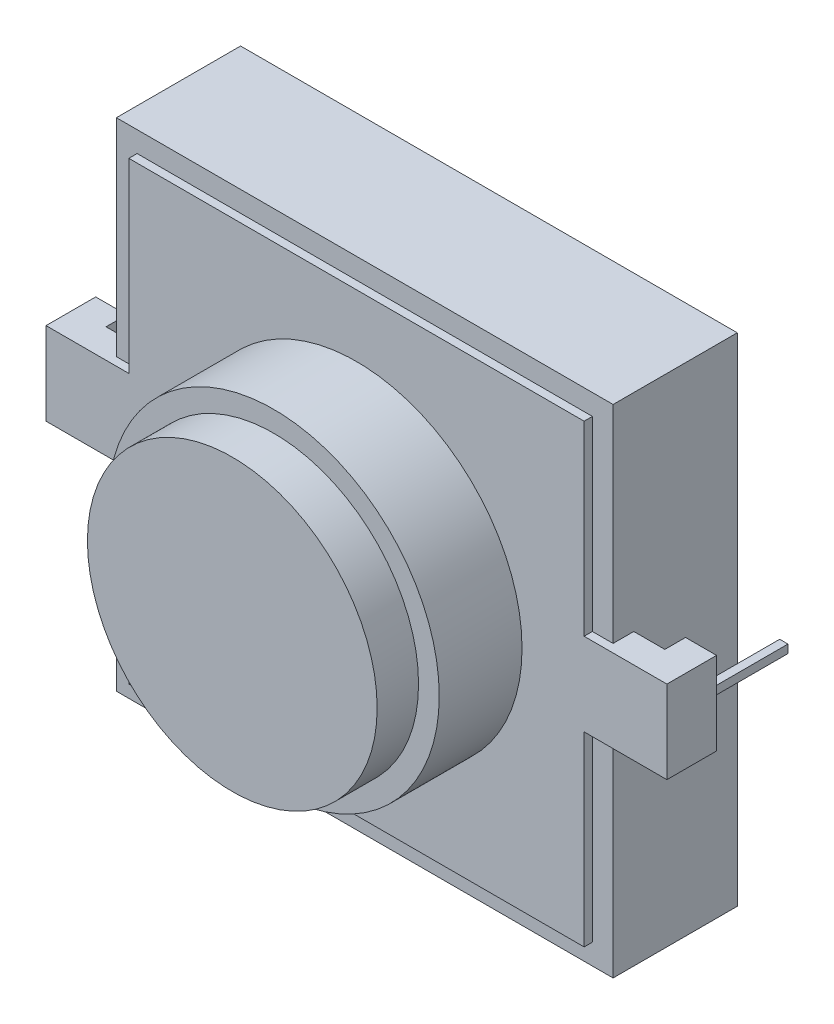
from build123d import *

# Parameters (mm, degrees)
ESQUISSE1_W             = 12
ESQUISSE1_H             = 12
BOSS_EXTRU_1_DEPTH      = 3
BOSS_EXTRU_2_DEPTH      = 0.2
BOSS_EXTRU_3_DEPTH      = 1
ESQUISSE4_W             = 0.2
ESQUISSE4_H             = 2
BOSS_EXTRU_4_DEPTH      = 0.1
ESQUISSE5_R             = 4
BOSS_EXTRU_5_DEPTH      = 2
ESQUISSE6_R             = 3.5
ENL_V_MAT_EXTRU_1_DEPTH = 2
ESQUISSE7_R             = 3.5
BOSS_EXTRU_6_DEPTH      = 3


with BuildPart() as part:
    # Esquisse1 → Boss.-Extru.1 (new body)
    with BuildSketch(Plane.XY):
        Rectangle(ESQUISSE1_W, ESQUISSE1_H)
    extrude(amount=BOSS_EXTRU_1_DEPTH)

    # Esquisse2 → Boss.-Extru.2 (add)
    with BuildSketch(Plane.XY.offset(3)):
        Polygon((-5.5, 1), (-5.5, 5.5), (5.5, 5.5), (5.5, 1), (7.5, 1), (7.5, -1), (5.5, -1), (5.5, -5.5), (-5.5, -5.5), (-5.5, -1), (-7.5, -1), (-7.5, 1), align=None)
    extrude(amount=BOSS_EXTRU_2_DEPTH)

    # Esquisse3 → Boss.-Extru.3 (add, symmetric)
    with BuildSketch(Plane(origin=(0, 0, 0), x_dir=(1, 0, 0), z_dir=(0, 1, 0))):
        Polygon((6, -3), (6, -2.5), (6.75, -2.5), (6.75, -2), (7.5, -2), (7.5, -3), align=None)
        Polygon((-7.5, -3), (-6, -3), (-6, -2.5), (-6.75, -2.5), (-6.75, -2), (-7.5, -2), align=None)
    extrude(amount=BOSS_EXTRU_3_DEPTH, both=True)

    # Esquisse4 → Boss.-Extru.4 (add, symmetric)
    with BuildSketch(Plane(origin=(0, 0, 0), x_dir=(1, 0, 0), z_dir=(0, 1, 0))):
        with Locations((7.125, -1)):
            Rectangle(ESQUISSE4_W, ESQUISSE4_H)
        with Locations((-7.125, -1)):
            Rectangle(ESQUISSE4_W, ESQUISSE4_H)
    extrude(amount=BOSS_EXTRU_4_DEPTH, both=True)

    # Esquisse5 → Boss.-Extru.5 (add)
    with BuildSketch(Plane.XY.offset(3.2)):
        Circle(ESQUISSE5_R)
    extrude(amount=BOSS_EXTRU_5_DEPTH)

    # Esquisse6 → Enlèv. mat.-Extru.1 (cut)
    with BuildSketch(Plane.XY.offset(5.2)):
        Circle(ESQUISSE6_R)
    extrude(amount=-ENL_V_MAT_EXTRU_1_DEPTH, mode=Mode.SUBTRACT)

    # Esquisse7 → Boss.-Extru.6 (add)
    with BuildSketch(Plane.XY.offset(3.2)):
        Circle(ESQUISSE7_R)
    extrude(amount=BOSS_EXTRU_6_DEPTH)


solid = part.part
